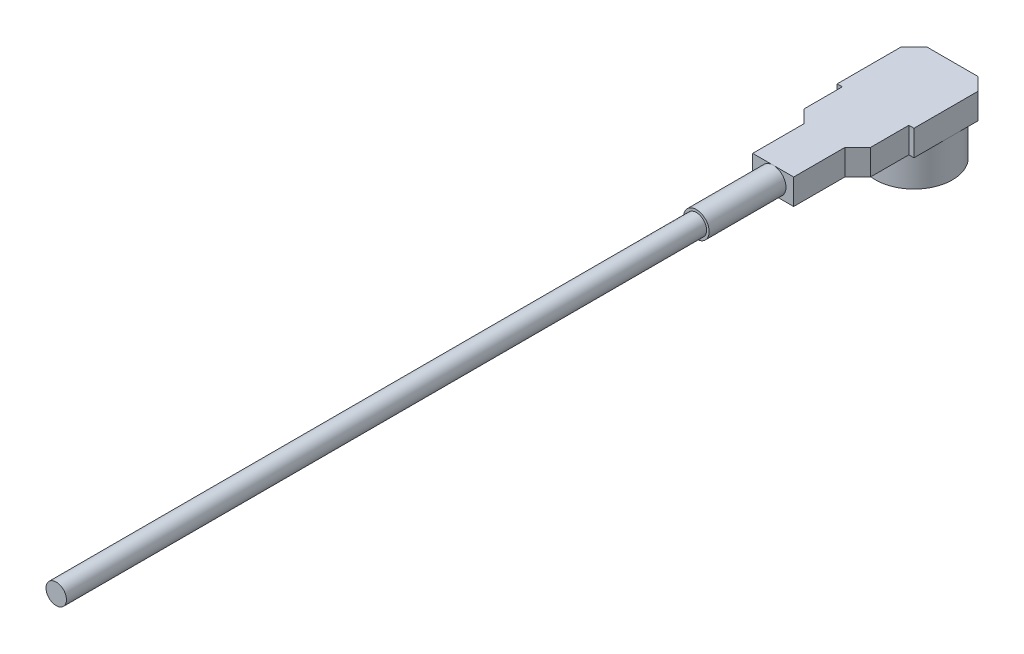
from build123d import *

# Parameters (mm, degrees)
SKETCH1_R           = 1.5
SKETCH1_R_2         = 1
BOSS_EXTRUDE1_DEPTH = 2.5
BOSS_EXTRUDE2_START = -1
SKETCH2_R           = 1
BOSS_EXTRUDE2_DEPTH = 1
SKETCH3_R           = 0.5
SKETCH3_R_2         = 0.4
BOSS_EXTRUDE3_DEPTH = 3
SKETCH3_3_R         = 0.4
BOSS_EXTRUDE4_DEPTH = 28
BOSS_EXTRUDE5_DEPTH = 1


with BuildPart() as part:
    # Sketch1 → Boss-Extrude1 (new body)
    with BuildSketch(Plane(origin=(0, 0, 0), x_dir=(1, 0, 0), z_dir=(0, 1, 0))):
        Circle(SKETCH1_R)
        Circle(SKETCH1_R_2, mode=Mode.SUBTRACT)
    extrude(amount=BOSS_EXTRUDE1_DEPTH)

    # Sketch2 → Boss-Extrude2 (add)
    with BuildSketch(Plane(origin=(0, 2.5, 0), x_dir=(1, 0, 0), z_dir=(0, 1, 0)).offset(BOSS_EXTRUDE2_START)):
        Polygon((1.3, -3), (1.3, -1.5), (1.5, -1.5), (1.5, 1), (1, 1.5), (-1, 1.5), (-1.5, 1), (-1.5, -1.5), (-1.3, -1.5), (-1.3, -3), (-0.8, -3.5), (-0.8, -5.5), (0.8, -5.5), (0.8, -3.5), align=None)
        Circle(SKETCH2_R, mode=Mode.SUBTRACT)
    extrude(amount=BOSS_EXTRUDE2_DEPTH)

    # Sketch3 → Boss-Extrude3 (add)
    with BuildSketch(Plane.XY.offset(5.5)):
        with Locations((0, 2)):
            Circle(SKETCH3_R)
        with Locations((0, 2)):
            Circle(SKETCH3_R_2, mode=Mode.SUBTRACT)
    extrude(amount=BOSS_EXTRUDE3_DEPTH)

    # Sketch3_3 → Boss-Extrude4 (add)
    with BuildSketch(Plane.XY.offset(5.5)):
        with Locations((0, 2)):
            Circle(SKETCH3_3_R)
    extrude(amount=BOSS_EXTRUDE4_DEPTH)

    # Sketch4 → Boss-Extrude5 (add)
    with BuildSketch(Plane(origin=(0, 2.5, 0), x_dir=(1, 0, 0), z_dir=(0, 1, 0))):
        Polygon((1.3, -1.5), (1.5, -1.5), (1.5, 1), (1, 1.5), (-1, 1.5), (-1.5, 1), (-1.5, -1.5), (-1.3, -1.5), (-1.3, -3), (-0.8, -3.5), (-0.8, -5.5), (0, -5.5), (0.8, -5.5), (0.8, -3.5), (1.3, -3), align=None)
    extrude(amount=-BOSS_EXTRUDE5_DEPTH)


solid = part.part
